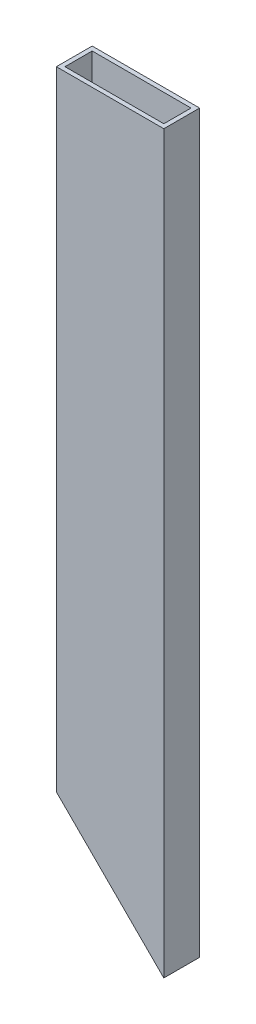
from build123d import *

# Parameters (mm, degrees)
SKETCH1_W               = 76.2
SKETCH1_H               = 25.4
SKETCH1_W_2             = 70.104
SKETCH1_H_2             = 19.304
BOSS_EXTRUDE1_DEPTH     = 445.4
SKETCH3_W               = 76.2
SKETCH3_H               = 25.4
SKETCH3_W_2             = 70.104
SKETCH3_H_2             = 19.304
BOSS_EXTRUDE2_DEPTH     = 38.1
SKETCH4_W               = 76.2
SKETCH4_H               = 25.4
SKETCH4_W_2             = 70.104
SKETCH4_H_2             = 19.304
BOSS_EXTRUDE3_DEPTH     = 38.1
CUT_EXTRUDE1_DEPTH      = 1
CUT_EXTRUDE1_DEPTH_BACK = 30.174377197


with BuildPart() as part:
    # Sketch1 → Boss-Extrude1 (new body)
    with BuildSketch(Plane(origin=(0, 0, 0), x_dir=(1, 0, 0), z_dir=(0, 1, 0))):
        Rectangle(SKETCH1_W, SKETCH1_H)
        Rectangle(SKETCH1_W_2, SKETCH1_H_2, mode=Mode.SUBTRACT)
    extrude(amount=BOSS_EXTRUDE1_DEPTH)

    # Sketch3 → Boss-Extrude2 (add)
    with BuildSketch(Plane.XZ):
        Rectangle(SKETCH3_W, SKETCH3_H)
        Rectangle(SKETCH3_W_2, SKETCH3_H_2, mode=Mode.SUBTRACT)
    extrude(amount=BOSS_EXTRUDE2_DEPTH)

    # Sketch4 → Boss-Extrude3 (add)
    with BuildSketch(Plane(origin=(0, 445.4, 0), x_dir=(1, 0, 0), z_dir=(0, 1, 0))):
        Rectangle(SKETCH4_W, SKETCH4_H)
        Rectangle(SKETCH4_W_2, SKETCH4_H_2, mode=Mode.SUBTRACT)
    extrude(amount=BOSS_EXTRUDE3_DEPTH)

    # Sketch5 → Cut-Extrude1 (cut, two sides)
    with BuildSketch(Plane(origin=(-495.613047426, 291.462739868, 16.474377197), x_dir=(0, 1, 0), z_dir=(0, 0, 1))) as cut_extrude1_sk:
        Polygon((-229.071966187, -433.222273746), (-421.383706246, -625.534013804), (-421.383706246, -336.978494197), align=None)
    extrude(amount=CUT_EXTRUDE1_DEPTH, mode=Mode.SUBTRACT)
    extrude(cut_extrude1_sk.sketch, amount=-CUT_EXTRUDE1_DEPTH_BACK, mode=Mode.SUBTRACT)


solid = part.part
